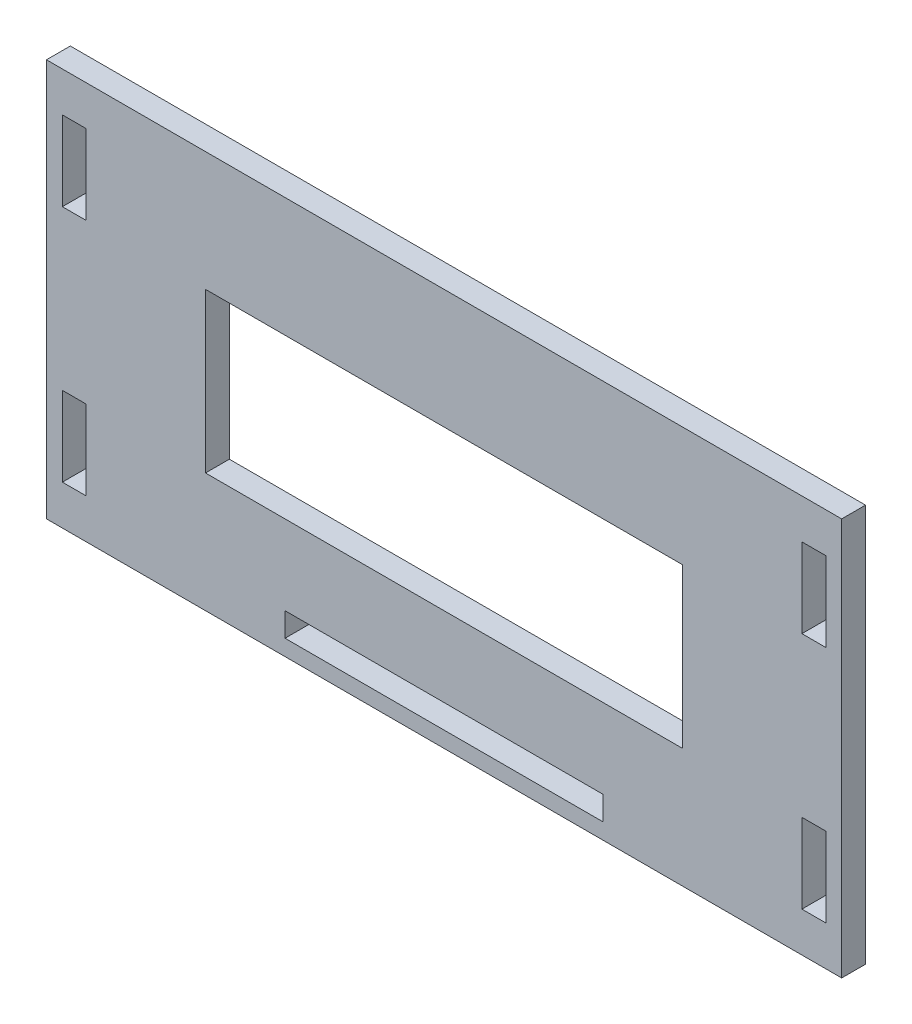
from build123d import *

# Parameters (mm, degrees)
SKETCH3_W           = 100
SKETCH3_H           = 50
SKETCH3_W_2         = 40
SKETCH3_H_2         = 3
SKETCH3_W_3         = 3
SKETCH3_H_3         = 10
SKETCH3_W_4         = 60
SKETCH3_H_4         = 20
BOSS_EXTRUDE2_DEPTH = 3


with BuildPart() as part:
    # Sketch3 → Boss-Extrude2 (new body)
    with BuildSketch(Plane.XY):
        Rectangle(SKETCH3_W, SKETCH3_H)
        with Locations((0, -21.5)):
            Rectangle(SKETCH3_W_2, SKETCH3_H_2, mode=Mode.SUBTRACT)
        with Locations((-46.5, 15)):
            Rectangle(SKETCH3_W_3, SKETCH3_H_3, mode=Mode.SUBTRACT)
        Rectangle(SKETCH3_W_4, SKETCH3_H_4, mode=Mode.SUBTRACT)
        with Locations((46.5, 15)):
            Rectangle(SKETCH3_W_3, SKETCH3_H_3, mode=Mode.SUBTRACT)
        with Locations((46.5, -15)):
            Rectangle(SKETCH3_W_3, SKETCH3_H_3, mode=Mode.SUBTRACT)
        with Locations((-46.5, -15)):
            Rectangle(SKETCH3_W_3, SKETCH3_H_3, mode=Mode.SUBTRACT)
    extrude(amount=BOSS_EXTRUDE2_DEPTH)


solid = part.part
